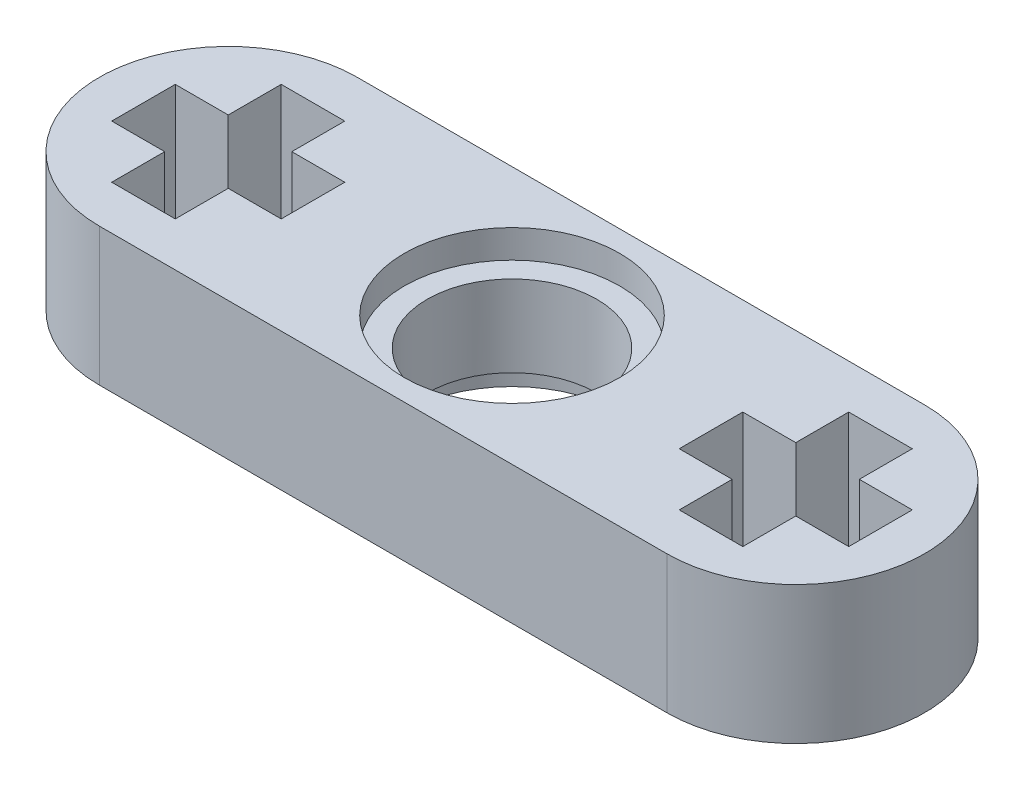
from build123d import *

# Parameters (mm, degrees)
SKETCH1_R           = 2.4
BOSS_EXTRUDE1_DEPTH = 3.9
SKETCH2_R           = 3.05
CUT_EXTRUDE1_DEPTH  = 0.8
SKETCH3_R           = 3.05
CUT_EXTRUDE2_DEPTH  = 0.8


with BuildPart() as part:
    # Sketch1 → Boss-Extrude1 (new body)
    with BuildSketch(Plane(origin=(0, 0, 0), x_dir=(1, 0, 0), z_dir=(0, 1, 0))):
        with BuildLine():
            Line((-8.035, 3.65), (8.035, 3.65))
            ThreePointArc((8.035, 3.65), (11.685, 0), (8.035, -3.65))
            Line((8.035, -3.65), (-8.035, -3.65))
            ThreePointArc((-8.035, -3.65), (-11.685, 0), (-8.035, 3.65))
        make_face()
        Circle(SKETCH1_R, mode=Mode.SUBTRACT)
        Polygon((7.135, 2.4), (7.135, 0.9), (5.635, 0.9), (5.635, -0.9), (7.135, -0.9), (7.135, -2.4), (8.935, -2.4), (8.935, -0.9), (10.435, -0.9), (10.435, 0.9), (8.935, 0.9), (8.935, 2.4), align=None, mode=Mode.SUBTRACT)
        Polygon((-8.934958517, 2.400106294), (-8.934958517, 0.900106294), (-10.434958517, 0.900106294), (-10.434958517, -0.899893706), (-8.934958517, -0.899893706), (-8.934958517, -2.399893706), (-7.134958517, -2.399893706), (-7.134958517, -0.899893706), (-5.634958517, -0.899893706), (-5.634958517, 0.900106294), (-7.134958517, 0.900106294), (-7.134958517, 2.400106294), align=None, mode=Mode.SUBTRACT)
    extrude(amount=BOSS_EXTRUDE1_DEPTH)

    # Sketch2 → Cut-Extrude1 (cut)
    with BuildSketch(Plane(origin=(0, 3.9, 0), x_dir=(1, 0, 0), z_dir=(0, 1, 0))):
        Circle(SKETCH2_R)
    extrude(amount=-CUT_EXTRUDE1_DEPTH, mode=Mode.SUBTRACT)

    # Sketch3 → Cut-Extrude2 (cut)
    with BuildSketch(Plane(origin=(0, 0, 0), x_dir=(-1, 0, 0), z_dir=(0, -1, 0))):
        Circle(SKETCH3_R)
    extrude(amount=-CUT_EXTRUDE2_DEPTH, mode=Mode.SUBTRACT)


solid = part.part
